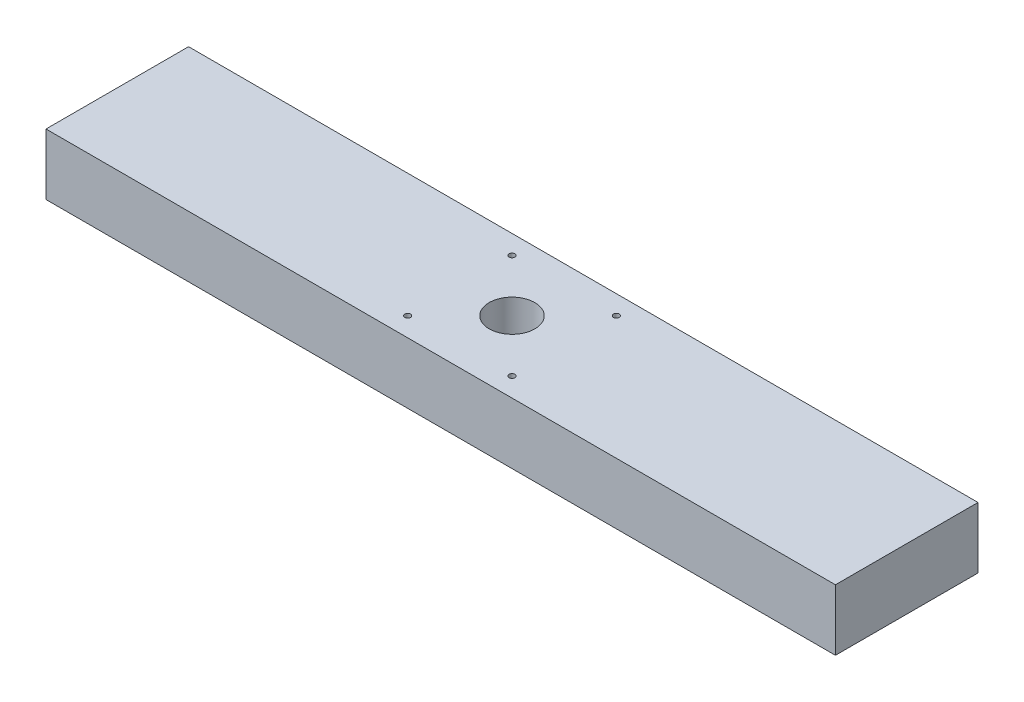
from build123d import *

# Parameters (mm, degrees)
SKETCH1_W           = 492.252
SKETCH1_H           = 88.9
BOSS_EXTRUDE1_DEPTH = 38.1
SKETCH2_R           = 1.8288
SKETCH2_R_2         = 14.224
CUT_EXTRUDE1_DEPTH  = 39.1


with BuildPart() as part:
    # Sketch1 → Boss-Extrude1 (new body)
    with BuildSketch(Plane(origin=(0, 0, 0), x_dir=(1, 0, 0), z_dir=(0, 1, 0))):
        Rectangle(SKETCH1_W, SKETCH1_H)
    extrude(amount=BOSS_EXTRUDE1_DEPTH)

    # Sketch2 → Cut-Extrude1 (cut, through all)
    with BuildSketch(Plane(origin=(0, 38.1, 0), x_dir=(1, 0, 0), z_dir=(0, 1, 0))):
        with Locations((-32.5501, 32.5501)):
            Circle(SKETCH2_R)
        with Locations((-32.5501, -32.5501)):
            Circle(SKETCH2_R)
        with Locations((32.5501, -32.5501)):
            Circle(SKETCH2_R)
        with Locations((32.5501, 32.5501)):
            Circle(SKETCH2_R)
        Circle(SKETCH2_R_2)
    extrude(amount=-CUT_EXTRUDE1_DEPTH, mode=Mode.SUBTRACT)


solid = part.part
